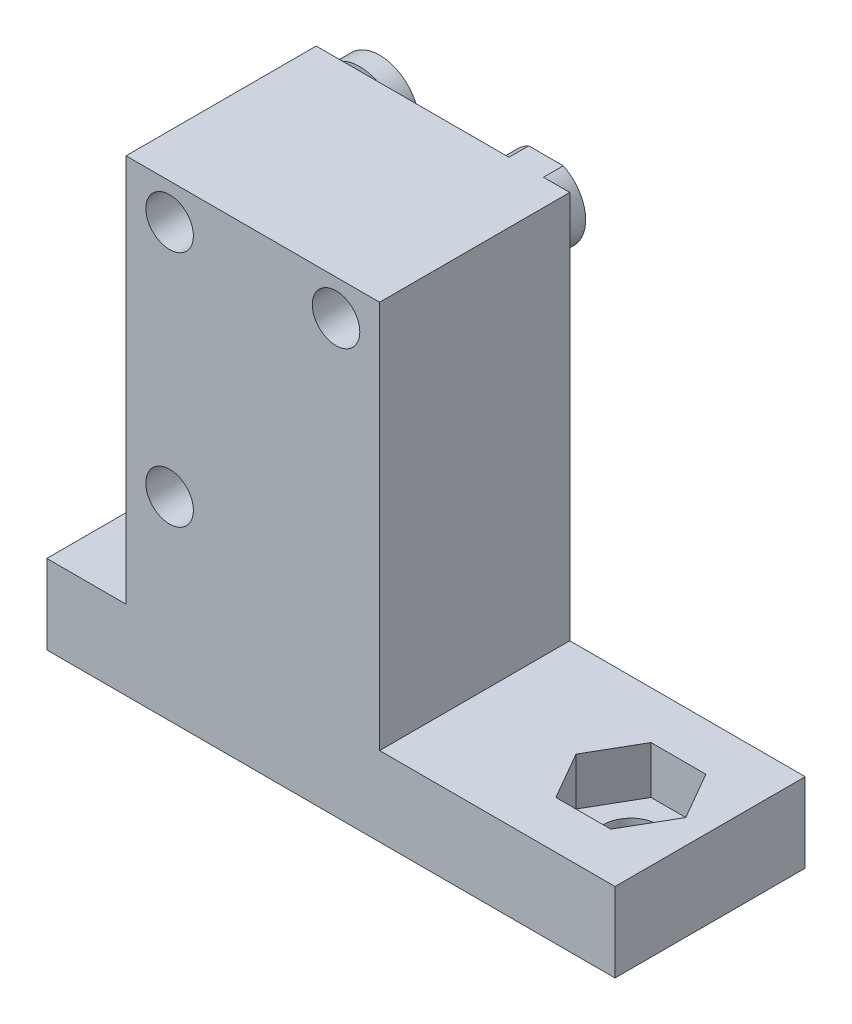
from build123d import *

# Parameters (mm, degrees)
SKETCH1_R             = 2.5
SKETCH1_R_2           = 1.5
BOSS_EXTRUDE1_DEPTH   = 1.25
BOSS_EXTRUDE1_2_DEPTH = 1.25
BOSS_EXTRUDE1_3_DEPTH = 1.25
BOSS_EXTRUDE2_START   = 1.25
SKETCH1_3_W           = 16
SKETCH1_3_H           = 29.4
SKETCH1_3_R           = 2.5
SKETCH1_3_R_2         = 1.5
BOSS_EXTRUDE2_DEPTH   = 12
SKETCH2_W             = 35.854037965
SKETCH2_H             = 12
BOSS_EXTRUDE3_DEPTH   = 5
SKETCH2_3_W           = 35.854037965
SKETCH2_3_H           = 11
SKETCH2_3_R           = 1.75
SKETCH2_3_R_2         = 1.4
BOSS_EXTRUDE4_DEPTH   = 3
SKETCH2_4_R           = 1.4
CUT_EXTRUDE1_DEPTH    = 10
SKETCH2_5_R           = 1.75
BOSS_EXTRUDE5_DEPTH   = 2


with BuildPart() as part:
    # Sketch1 → Boss-Extrude1 (new body)
    with BuildSketch(Plane.XY):
        with Locations((2.75, 17.5)):
            Circle(SKETCH1_R)
        with Locations((2.75, 17.5)):
            Circle(SKETCH1_R_2, mode=Mode.SUBTRACT)
    extrude(amount=BOSS_EXTRUDE1_DEPTH)



with BuildPart() as body_2:
    # Sketch1 → Boss-Extrude1 2 (new body)
    with BuildSketch(Plane.XY):
        with BuildLine():
            Line((14.339724736, 19.75), (12.160275264, 19.75))
            ThreePointArc((12.160275264, 19.75), (13.25, 15), (14.339724736, 19.75))
        make_face()
        with Locations((13.25, 17.5)):
            Circle(SKETCH1_R_2, mode=Mode.SUBTRACT)
    extrude(amount=BOSS_EXTRUDE1_2_DEPTH)


with BuildPart() as body_3:
    # Sketch1 → Boss-Extrude1 3 (new body)
    with BuildSketch(Plane.XY):
        with Locations((2.75, 2.5)):
            Circle(SKETCH1_R)
        with Locations((2.75, 2.5)):
            Circle(SKETCH1_R_2, mode=Mode.SUBTRACT)
    extrude(amount=BOSS_EXTRUDE1_3_DEPTH)


with BuildPart() as part_1:
    add(part.part)

    add(body_2.part)  # Boss-Extrude2 merges body 2

    add(body_3.part)  # Boss-Extrude2 merges body 3
    # Sketch1_3 → Boss-Extrude2 (add)
    with BuildSketch(Plane.XY.offset(BOSS_EXTRUDE2_START)):
        with Locations((8, 5.05)):
            Rectangle(SKETCH1_3_W, SKETCH1_3_H)
        with Locations((13.25, 17.5)):
            Circle(SKETCH1_3_R, mode=Mode.SUBTRACT)
        with Locations((2.75, 17.5)):
            Circle(SKETCH1_3_R, mode=Mode.SUBTRACT)
        with Locations((2.75, 2.5)):
            Circle(SKETCH1_3_R, mode=Mode.SUBTRACT)
        with Locations((2.75, 2.5)):
            Circle(SKETCH1_3_R)
        with Locations((2.75, 2.5)):
            Circle(SKETCH1_3_R_2, mode=Mode.SUBTRACT)
        with BuildLine():
            Line((3.839724736, 19.75), (1.660275264, 19.75))
            ThreePointArc((1.660275264, 19.75), (1.422278614, 15.381709198), (5.25, 17.5))
            ThreePointArc((5.25, 17.5), (4.868290802, 18.827721386), (3.839724736, 19.75))
        make_face()
        with Locations((2.75, 17.5)):
            Circle(SKETCH1_3_R_2, mode=Mode.SUBTRACT)
        with BuildLine():
            Line((14.339724736, 19.75), (12.160275264, 19.75))
            ThreePointArc((12.160275264, 19.75), (11.922278614, 15.381709198), (15.75, 17.5))
            ThreePointArc((15.75, 17.5), (15.368290802, 18.827721386), (14.339724736, 19.75))
        make_face()
        with Locations((13.25, 17.5)):
            Circle(SKETCH1_3_R_2, mode=Mode.SUBTRACT)
    extrude(amount=BOSS_EXTRUDE2_DEPTH)

    # Sketch2 → Boss-Extrude3 (add)
    with BuildSketch(Plane(origin=(0, -9.75, 0), x_dir=(1, 0, 0), z_dir=(0, 1, 0))):
        with Locations((12.927018983, -7.25)):
            Rectangle(SKETCH2_W, SKETCH2_H)
        Polygon((29.31813958, -7.25), (27.586088773, -4.25), (24.121987157, -4.25), (22.38993635, -7.25), (24.121987157, -10.25), (27.586088773, -10.25), align=None, mode=Mode.SUBTRACT)
    extrude(amount=BOSS_EXTRUDE3_DEPTH)

    # Sketch2_3 → Boss-Extrude4 (add)
    with BuildSketch(Plane(origin=(0, -9.75, 0), x_dir=(1, 0, 0), z_dir=(0, 1, 0))):
        with Locations((12.927018983, -7.25)):
            Rectangle(SKETCH2_3_W, SKETCH2_3_H)
        with Locations((0.854037965, -7.25)):
            Circle(SKETCH2_3_R, mode=Mode.SUBTRACT)
        Polygon((27.586088773, -4.25), (29.31813958, -7.25), (27.586088773, -10.25), (24.121987157, -10.25), (22.38993635, -7.25), (24.121987157, -4.25), align=None, mode=Mode.SUBTRACT)
        with Locations((0.854037965, -7.25)):
            Circle(SKETCH2_3_R_2)
    extrude(amount=BOSS_EXTRUDE4_DEPTH)

    # Sketch2_4 → Cut-Extrude1 (cut)
    with BuildSketch(Plane(origin=(0, -9.75, 0), x_dir=(1, 0, 0), z_dir=(0, 1, 0))):
        with Locations((0.854037965, -7.25)):
            Circle(SKETCH2_4_R)
    extrude(amount=CUT_EXTRUDE1_DEPTH, mode=Mode.SUBTRACT)

    # Sketch2_5 → Boss-Extrude5 (add)
    with BuildSketch(Plane(origin=(0, -9.75, 0), x_dir=(1, 0, 0), z_dir=(0, 1, 0))):
        Polygon((24.121987157, -10.25), (27.586088773, -10.25), (29.31813958, -7.25), (27.586088773, -4.25), (24.121987157, -4.25), (22.38993635, -7.25), align=None)
        with Locations((25.854037965, -7.25)):
            Circle(SKETCH2_5_R, mode=Mode.SUBTRACT)
    extrude(amount=BOSS_EXTRUDE5_DEPTH)


solid = part_1.part
